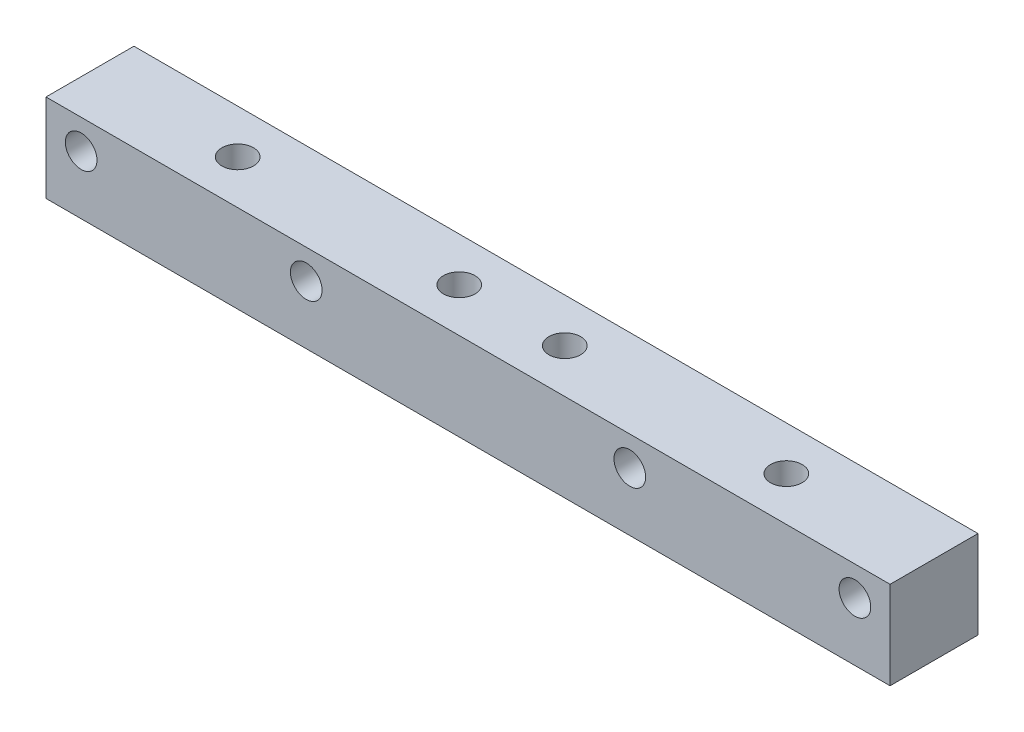
from build123d import *

# Parameters (mm, degrees)
SKETCH1_W             = 12.5
SKETCH1_H             = 12.5
BOSS_EXTRUDE1_DEPTH   = 60
F_4_0MM_DOWEL_HOLE1_D = 4.5
F_1_0MM_DOWEL_HOLE1_D = 4.5


with BuildPart() as part:
    # Sketch1 → Boss-Extrude1 (new body, symmetric)
    with BuildSketch(Plane(origin=(0, 0, 0), x_dir=(0, 0, -1), z_dir=(1, 0, 0))):
        Rectangle(SKETCH1_W, SKETCH1_H)
    extrude(amount=BOSS_EXTRUDE1_DEPTH, both=True)

    # Ø4.0mm Dowel Hole1 (through all)
    with Locations(Plane.XY.offset(6.25)):
        with Locations((-55, 2.07), (-23, 2.07), (23, 2.07), (55, 2.07)):
            Hole(F_4_0MM_DOWEL_HOLE1_D / 2)

    # Ø1.0mm Dowel Hole1 (through all)
    with Locations(Plane(origin=(0, 6.25, 0), x_dir=(1, 0, 0), z_dir=(0, 1, 0))):
        with Locations((-39, 0), (39, 0), (-7.5, 0), (7.5, 0)):
            Hole(F_1_0MM_DOWEL_HOLE1_D / 2)


solid = part.part
